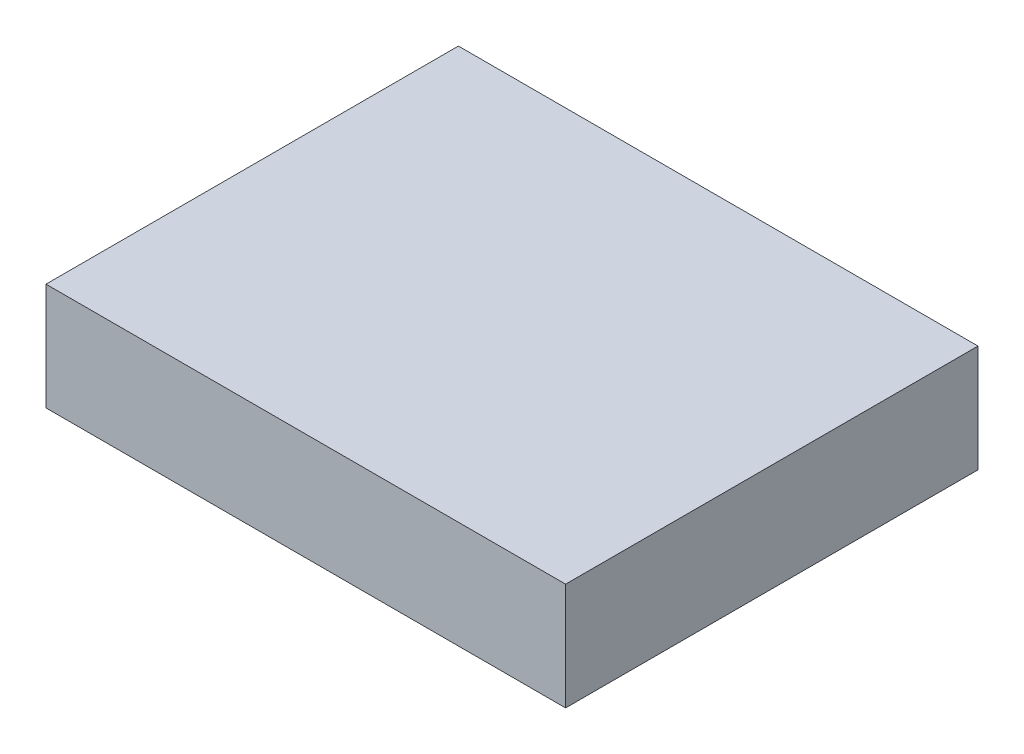
from build123d import *

# Parameters (mm, degrees)
SKETCH2_W           = 160.02
SKETCH2_H           = 127
BOSS_EXTRUDE2_DEPTH = 33.02


with BuildPart() as part:
    # Sketch2 → Boss-Extrude2 (new body)
    with BuildSketch(Plane(origin=(0, 0, 0), x_dir=(1, 0, 0), z_dir=(0, 1, 0))):
        Rectangle(SKETCH2_W, SKETCH2_H)
    extrude(amount=BOSS_EXTRUDE2_DEPTH)


solid = part.part
